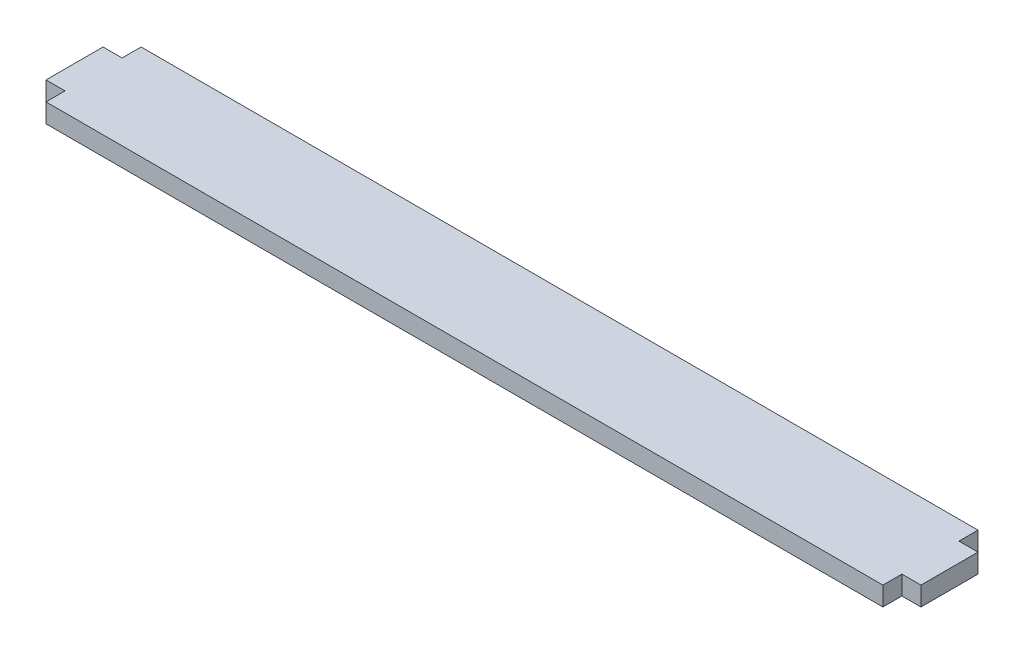
from build123d import *

# Parameters (mm, degrees)
BOSS_EXTRUDE1_DEPTH = 3.175


with BuildPart() as part:
    # Sketch1 → Boss-Extrude1 (new body)
    with BuildSketch(Plane(origin=(0, 0, 0), x_dir=(1, 0, 0), z_dir=(0, 1, 0))):
        Polygon((-69.85, -7.9375), (69.85, -7.9375), (69.85, -4.7625), (73.025, -4.7625), (73.025, 4.7625), (69.85, 4.7625), (69.85, 7.9375), (-69.85, 7.9375), (-69.85, 4.7625), (-73.025, 4.7625), (-73.025, -4.7625), (-69.85, -4.7625), align=None)
    extrude(amount=BOSS_EXTRUDE1_DEPTH)


solid = part.part
